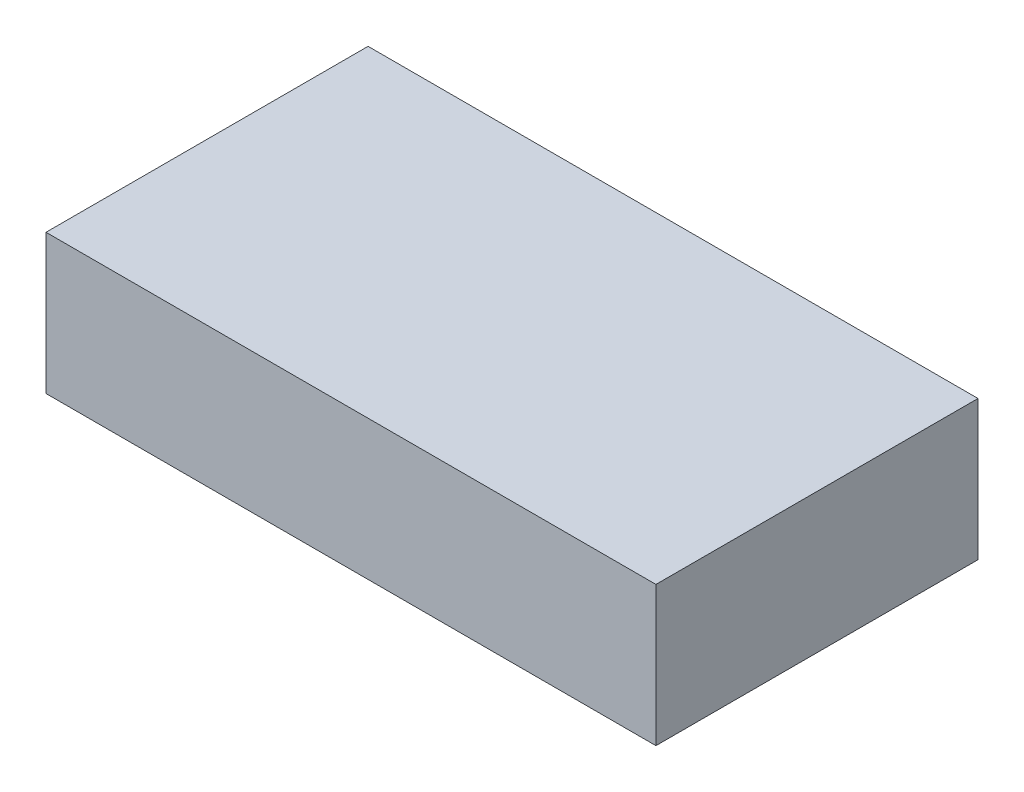
from build123d import *

# Parameters (mm, degrees)
SKETCH2_W           = 214
SKETCH2_H           = 113
BOSS_EXTRUDE1_DEPTH = 49


with BuildPart() as part:
    # Sketch2 → Boss-Extrude1 (new body)
    with BuildSketch(Plane(origin=(0, 0, 0), x_dir=(1, 0, 0), z_dir=(0, 1, 0))):
        with Locations((107, 56.5)):
            Rectangle(SKETCH2_W, SKETCH2_H)
    extrude(amount=BOSS_EXTRUDE1_DEPTH)


solid = part.part
